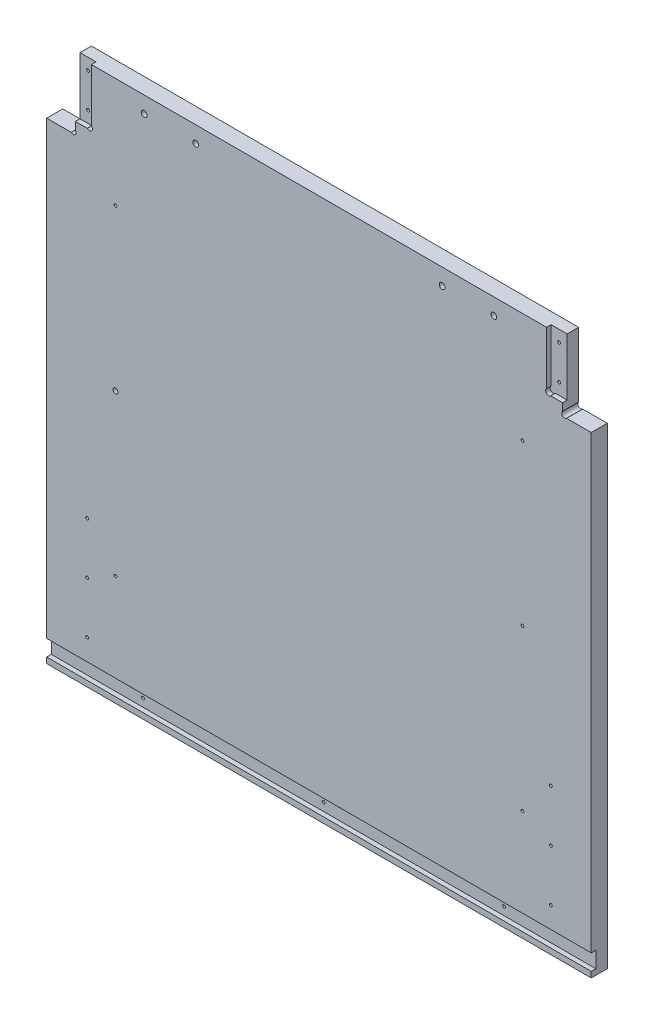
from build123d import *

# Parameters (mm, degrees)
EXTRUDE1_DEPTH     = 17.78
SKETCH4_R          = 3.175000003
SKETCH4_R_2        = 3.175000002
CUT_EXTRUDE1_DEPTH = 17.78
SKETCH6_R          = 1.5875
SKETCH6_R_2        = 1.587500002
SKETCH6_R_3        = 2.777849083
CUT_EXTRUDE3_DEPTH = 17.78
SKETCH5_W          = 17.78
SKETCH5_H          = 63.50740041
SKETCH5_H_2        = 63.507400408
CUT_EXTRUDE2_DEPTH = 5.08
SKETCH7_R          = 3.302
SKETCH7_R_2        = 3.302000002
CUT_EXTRUDE4_DEPTH = 5.08
SKETCH9_R          = 3.175
CUT_EXTRUDE5_DEPTH = 17.78


with BuildPart() as part:
    # Sketch3 → Extrude1 (new body)
    with BuildSketch(Plane.XY):
        Polygon((10806.641666666, -6342.0625), (11409.891666666, -6342.0625), (11409.891666666, -5818.736838581), (11378.141666665, -5818.736838581), (11378.141666665, -5742.536838581), (10838.391666667, -5742.536838581), (10838.391666667, -5818.736838581), (10806.641666666, -5818.736838581), align=None)
    extrude(amount=-EXTRUDE1_DEPTH)

    # Sketch4 → Cut-Extrude1 (cut)
    with BuildSketch(Plane.XY):
        with Locations((11380.386730695, -5816.491774551)):
            Circle(SKETCH4_R)
        with Locations((10836.146602637, -5816.491774551)):
            Circle(SKETCH4_R_2)
    extrude(amount=-CUT_EXTRUDE1_DEPTH, mode=Mode.SUBTRACT)

    # Sketch6 → Cut-Extrude3 (cut)
    with BuildSketch(Plane.XY):
        with Locations((10851.409166666, -6294.4375)):
            Circle(SKETCH6_R)
        with Locations((10908.241666666, -6326.8225)):
            Circle(SKETCH6_R)
        with Locations((11108.266666666, -6326.8225)):
            Circle(SKETCH6_R)
        with Locations((11308.291666666, -6326.8225)):
            Circle(SKETCH6_R)
        with Locations((11365.124166666, -6294.4375)):
            Circle(SKETCH6_R)
        with Locations((11365.124166666, -6237.2875)):
            Circle(SKETCH6_R)
        with Locations((11333.691666666, -6220.099669291)):
            Circle(SKETCH6_R)
        with Locations((11365.124166666, -6180.1375)):
            Circle(SKETCH6_R)
        with Locations((11333.691666666, -6042.299669291)):
            Circle(SKETCH6_R)
        with Locations((11333.691666666, -5864.499669291)):
            Circle(SKETCH6_R)
        with Locations((11369.251666663, -5793.344238991)):
            Circle(SKETCH6_R_2)
        with Locations((11369.251666663, -5755.236838581)):
            Circle(SKETCH6_R_2)
        with Locations((10847.281666666, -5755.236838581)):
            Circle(SKETCH6_R)
        with Locations((10847.281666666, -5793.344238991)):
            Circle(SKETCH6_R)
        with Locations((10882.841666666, -6042.299669291)):
            Circle(SKETCH6_R_3)
        with Locations((10851.409166666, -6180.1375)):
            Circle(SKETCH6_R)
        with Locations((10882.841666666, -6220.099669291)):
            Circle(SKETCH6_R)
        with Locations((10851.409166666, -6237.2875)):
            Circle(SKETCH6_R)
        with Locations((10882.841666666, -5864.499669291)):
            Circle(SKETCH6_R)
    extrude(amount=-CUT_EXTRUDE3_DEPTH, mode=Mode.SUBTRACT)

    # Sketch5 → Cut-Extrude2 (cut)
    with BuildSketch(Plane.XY):
        Polygon((11108.266666666, -6317.9325), (10806.641666666, -6317.9325), (10806.641666666, -6335.7125), (11409.891666666, -6335.7125), (11409.891666666, -6317.9325), align=None)
        with Locations((10847.281666667, -5774.290538786)):
            Rectangle(SKETCH5_W, SKETCH5_H)
        with Locations((11369.251666665, -5774.290538785)):
            Rectangle(SKETCH5_W, SKETCH5_H_2)
    extrude(amount=-CUT_EXTRUDE2_DEPTH, mode=Mode.SUBTRACT)

    # Sketch7 → Cut-Extrude4 (cut)
    with BuildSketch(Plane.XY):
        with Locations((10853.926602637, -5803.79917496)):
            Circle(SKETCH7_R)
        with Locations((11362.606730695, -5803.799174959)):
            Circle(SKETCH7_R_2)
    extrude(amount=-CUT_EXTRUDE4_DEPTH, mode=Mode.SUBTRACT)

    # Sketch9 → Cut-Extrude5 (cut)
    with BuildSketch(Plane.XY):
        with Locations((10914.541654066, -5760.644320781)):
            Circle(SKETCH9_R)
        with Locations((10971.741666666, -5760.644320781)):
            Circle(SKETCH9_R)
        with Locations((11244.741654066, -5760.644320781)):
            Circle(SKETCH9_R)
        with Locations((11301.941666666, -5760.644320781)):
            Circle(SKETCH9_R)
    extrude(amount=-CUT_EXTRUDE5_DEPTH, mode=Mode.SUBTRACT)


solid = part.part
